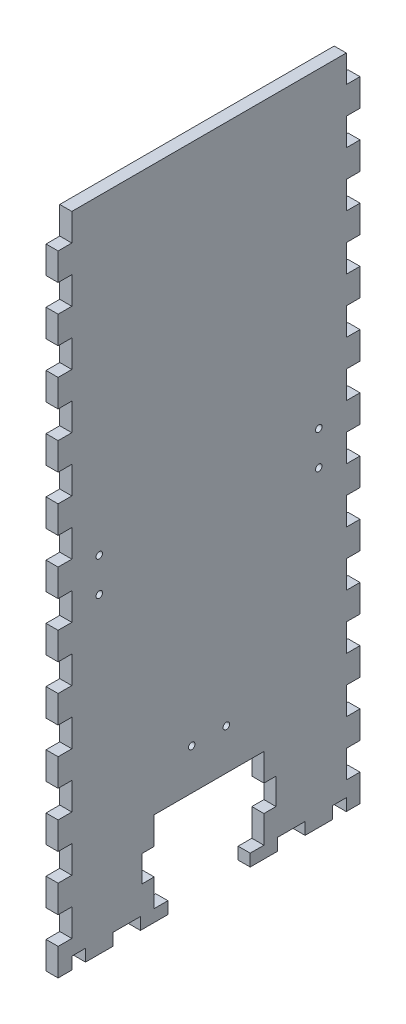
from build123d import *

# Parameters (mm, degrees)
SKETCH1_W              = 273.05
SKETCH1_H              = 139.7
BOSS_EXTRUDE1_DEPTH    = 5.588
SKETCH2_W              = 273.05
SKETCH2_H              = 139.7
SKETCH2_W_2            = 261.874
SKETCH2_H_2            = 128.524
BOSS_EXTRUDE2_DEPTH    = 298.45
SKETCH3_W              = 6.35
SKETCH3_H              = 16.933333333
SKETCH3_H_2            = 16.933333334
DOOR_SLOT_DEPTH        = 12.7
DOOR_GUIDE_HOLES_REACH = 361.255
SKETCH4_W              = 6.35
SKETCH4_H              = 15.875
LEVER_HOLES_W          = 9.652
LEVER_HOLES_H          = 6.35
LEVER_HOLES_W_2        = 6.35
CUT_EXTRUDE1_DEPTH     = 362.378293578
CUT_EXTRUDE3_REACH     = 416.577
SKETCH8_R              = 3.175
SKETCH16_W             = 327.238778096
SKETCH16_H             = 314.471565403
CUT_EXTRUDE10_DEPTH    = 362.378293578
LEFT_RIGHT_W           = 6.35
LEFT_RIGHT_H           = 5.588
LEFT_RIGHT_W_2         = 12.7
LEFT_RIGHT_H_2         = 12.66825
CUT_EXTRUDE11_DEPTH    = 415.577411883
SKETCH17_R             = 1.5
SKETCH17_W             = 23
SKETCH17_H             = 17.61800007
CUT_EXTRUDE12_DEPTH    = 313.00857951
SKETCH18_W             = 5.588
SKETCH18_H             = 12.192
CUT_EXTRUDE13_DEPTH    = 313.00857951


with BuildPart() as part:
    # Sketch1 → Boss-Extrude1 (new body)
    with BuildSketch(Plane(origin=(0, 0, 0), x_dir=(1, 0, 0), z_dir=(0, 1, 0))):
        Rectangle(SKETCH1_W, SKETCH1_H)
    extrude(amount=BOSS_EXTRUDE1_DEPTH)

    # Sketch2 → Boss-Extrude2 (add)
    with BuildSketch(Plane(origin=(0, 5.588, 0), x_dir=(1, 0, 0), z_dir=(0, 1, 0))):
        Rectangle(SKETCH2_W, SKETCH2_H)
        Rectangle(SKETCH2_W_2, SKETCH2_H_2, mode=Mode.SUBTRACT)
    extrude(amount=BOSS_EXTRUDE2_DEPTH)

    # Sketch3 → Door Slot (cut)
    with BuildSketch(Plane.XY.offset(69.85)):
        with BuildLine():
            Line((-29.337, 282.448), (-29.337, 5.588))
            Line((-29.337, 5.588), (-22.733, 5.588))
            Line((-22.733, 5.588), (-22.733, 291.592))
            Line((-22.733, 291.592), (-42.291, 291.592))
            Line((-42.291, 291.592), (-42.291, 284.988))
            Line((-42.291, 284.988), (-31.877, 284.988))
            ThreePointArc((-31.877, 284.988), (-30.080948776, 284.244051224), (-29.337, 282.448))
        make_face()
        with Locations((-13.208, 80.433333334)):
            Rectangle(SKETCH3_W, SKETCH3_H)
        with Locations((-13.208, 50.8)):
            Rectangle(SKETCH3_W, SKETCH3_H_2)
        with Locations((-13.208, 21.166666667)):
            Rectangle(SKETCH3_W, SKETCH3_H)
    extrude(amount=-DOOR_SLOT_DEPTH, mode=Mode.SUBTRACT)

    # Sketch4 → Door Guide Holes (cut, up to next)
    with BuildSketch(Plane.XY.offset(-64.262), mode=Mode.PRIVATE) as door_guide_holes_sk1:
        with Locations((-45.466, 283.4005)):
            Rectangle(SKETCH4_W, SKETCH4_H)
    door_guide_holes_tool1 = extrude(door_guide_holes_sk1.sketch, amount=-DOOR_GUIDE_HOLES_REACH, mode=Mode.PRIVATE) & part.part
    # Sketch4 → Door Guide Holes (cut, up to next)
    with BuildSketch(Plane.XY.offset(-64.262), mode=Mode.PRIVATE) as door_guide_holes_sk2:
        with Locations((-45.466, 254.8255)):
            Rectangle(SKETCH4_W, SKETCH4_H)
    door_guide_holes_tool2 = extrude(door_guide_holes_sk2.sketch, amount=-DOOR_GUIDE_HOLES_REACH, mode=Mode.PRIVATE) & part.part
    # Sketch4 → Door Guide Holes (cut, up to next)
    with BuildSketch(Plane.XY.offset(-64.262), mode=Mode.PRIVATE) as door_guide_holes_sk3:
        with Locations((-45.466, 226.2505)):
            Rectangle(SKETCH4_W, SKETCH4_H)
    door_guide_holes_tool3 = extrude(door_guide_holes_sk3.sketch, amount=-DOOR_GUIDE_HOLES_REACH, mode=Mode.PRIVATE) & part.part
    # Sketch4 → Door Guide Holes (cut, up to next)
    with BuildSketch(Plane.XY.offset(-64.262), mode=Mode.PRIVATE) as door_guide_holes_sk4:
        with Locations((-45.466, 197.6755)):
            Rectangle(SKETCH4_W, SKETCH4_H)
    door_guide_holes_tool4 = extrude(door_guide_holes_sk4.sketch, amount=-DOOR_GUIDE_HOLES_REACH, mode=Mode.PRIVATE) & part.part
    # Sketch4 → Door Guide Holes (cut, up to next)
    with BuildSketch(Plane.XY.offset(-64.262), mode=Mode.PRIVATE) as door_guide_holes_sk5:
        with Locations((-45.466, 169.1005)):
            Rectangle(SKETCH4_W, SKETCH4_H)
    door_guide_holes_tool5 = extrude(door_guide_holes_sk5.sketch, amount=-DOOR_GUIDE_HOLES_REACH, mode=Mode.PRIVATE) & part.part
    # Sketch4 → Door Guide Holes (cut, up to next)
    with BuildSketch(Plane.XY.offset(-64.262), mode=Mode.PRIVATE) as door_guide_holes_sk6:
        with Locations((-45.466, 140.5255)):
            Rectangle(SKETCH4_W, SKETCH4_H)
    door_guide_holes_tool6 = extrude(door_guide_holes_sk6.sketch, amount=-DOOR_GUIDE_HOLES_REACH, mode=Mode.PRIVATE) & part.part
    # Sketch4 → Door Guide Holes (cut, up to next)
    with BuildSketch(Plane.XY.offset(-64.262), mode=Mode.PRIVATE) as door_guide_holes_sk7:
        with Locations((-45.466, 111.9505)):
            Rectangle(SKETCH4_W, SKETCH4_H)
    door_guide_holes_tool7 = extrude(door_guide_holes_sk7.sketch, amount=-DOOR_GUIDE_HOLES_REACH, mode=Mode.PRIVATE) & part.part
    # Sketch4 → Door Guide Holes (cut, up to next)
    with BuildSketch(Plane.XY.offset(-64.262), mode=Mode.PRIVATE) as door_guide_holes_sk8:
        with Locations((-45.466, 83.3755)):
            Rectangle(SKETCH4_W, SKETCH4_H)
    door_guide_holes_tool8 = extrude(door_guide_holes_sk8.sketch, amount=-DOOR_GUIDE_HOLES_REACH, mode=Mode.PRIVATE) & part.part
    # Sketch4 → Door Guide Holes (cut, up to next)
    with BuildSketch(Plane.XY.offset(-64.262), mode=Mode.PRIVATE) as door_guide_holes_sk9:
        with Locations((-45.466, 54.8005)):
            Rectangle(SKETCH4_W, SKETCH4_H)
    door_guide_holes_tool9 = extrude(door_guide_holes_sk9.sketch, amount=-DOOR_GUIDE_HOLES_REACH, mode=Mode.PRIVATE) & part.part
    # Sketch4 → Door Guide Holes (cut, up to next)
    with BuildSketch(Plane.XY.offset(-64.262), mode=Mode.PRIVATE) as door_guide_holes_sk10:
        with Locations((-45.466, 26.2255)):
            Rectangle(SKETCH4_W, SKETCH4_H)
    door_guide_holes_tool10 = extrude(door_guide_holes_sk10.sketch, amount=-DOOR_GUIDE_HOLES_REACH, mode=Mode.PRIVATE) & part.part
    door_guide_holes_1 = door_guide_holes_tool1.solids().sort_by_distance((-45.466, 283.4005, -64.262))[0]
    add(door_guide_holes_1, mode=Mode.SUBTRACT)
    door_guide_holes_2 = door_guide_holes_tool2.solids().sort_by_distance((-45.466, 254.8255, -64.262))[0]
    add(door_guide_holes_2, mode=Mode.SUBTRACT)
    door_guide_holes_3 = door_guide_holes_tool3.solids().sort_by_distance((-45.466, 226.2505, -64.262))[0]
    add(door_guide_holes_3, mode=Mode.SUBTRACT)
    door_guide_holes_4 = door_guide_holes_tool4.solids().sort_by_distance((-45.466, 197.6755, -64.262))[0]
    add(door_guide_holes_4, mode=Mode.SUBTRACT)
    door_guide_holes_5 = door_guide_holes_tool5.solids().sort_by_distance((-45.466, 169.1005, -64.262))[0]
    add(door_guide_holes_5, mode=Mode.SUBTRACT)
    door_guide_holes_6 = door_guide_holes_tool6.solids().sort_by_distance((-45.466, 140.5255, -64.262))[0]
    add(door_guide_holes_6, mode=Mode.SUBTRACT)
    door_guide_holes_7 = door_guide_holes_tool7.solids().sort_by_distance((-45.466, 111.9505, -64.262))[0]
    add(door_guide_holes_7, mode=Mode.SUBTRACT)
    door_guide_holes_8 = door_guide_holes_tool8.solids().sort_by_distance((-45.466, 83.3755, -64.262))[0]
    add(door_guide_holes_8, mode=Mode.SUBTRACT)
    door_guide_holes_9 = door_guide_holes_tool9.solids().sort_by_distance((-45.466, 54.8005, -64.262))[0]
    add(door_guide_holes_9, mode=Mode.SUBTRACT)
    door_guide_holes_10 = door_guide_holes_tool10.solids().sort_by_distance((-45.466, 26.2255, -64.262))[0]
    add(door_guide_holes_10, mode=Mode.SUBTRACT)
    door_guide_holes = door_guide_holes_1 + door_guide_holes_2 + door_guide_holes_3 + door_guide_holes_4 + door_guide_holes_5 + door_guide_holes_6 + door_guide_holes_7 + door_guide_holes_8 + door_guide_holes_9 + door_guide_holes_10  # Door Guide Holes as one shape, for the pattern or mirror that repeats it

    # Mirror1: Door Guide Holes across plane
    add(door_guide_holes.mirror(Plane.ZY.offset(32.512)), mode=Mode.SUBTRACT)

    # Lever Holes → Cut-Extrude1 (cut, through all)
    with BuildSketch(Plane.XY.offset(69.85)):
        with Locations((54.102, 28.575)):
            Rectangle(LEVER_HOLES_W, LEVER_HOLES_H)
        with Locations((39.3065, 15.875)):
            Rectangle(LEVER_HOLES_W_2, LEVER_HOLES_H)
        with Locations((68.8975, 15.875)):
            Rectangle(LEVER_HOLES_W_2, LEVER_HOLES_H)
    extrude(amount=-CUT_EXTRUDE1_DEPTH, mode=Mode.SUBTRACT)

    # Sketch8 → Cut-Extrude3 (cut, up to next)
    with BuildSketch(Plane.ZY.offset(136.525), mode=Mode.PRIVATE) as cut_extrude3_sk1:
        with Locations((0, 19.05)):
            Circle(SKETCH8_R)
    cut_extrude3_tool1 = extrude(cut_extrude3_sk1.sketch, amount=-CUT_EXTRUDE3_REACH, mode=Mode.PRIVATE) & part.part
    add(cut_extrude3_tool1.solids().sort_by_distance((-136.525, 19.05, 0))[0], mode=Mode.SUBTRACT)

    # Sketch16 → Cut-Extrude10 (cut, through all)
    with BuildSketch(Plane.XY.offset(69.85)):
        with Locations((-32.682389048, 146.802217299)):
            Rectangle(SKETCH16_W, SKETCH16_H)
    extrude(amount=-CUT_EXTRUDE10_DEPTH, mode=Mode.SUBTRACT)

    # Left/Right → Cut-Extrude11 (cut, through all)
    with BuildSketch(Plane.ZY.offset(136.525)):
        with Locations((60.325, 2.794)):
            Rectangle(LEFT_RIGHT_W, LEFT_RIGHT_H)
        with Locations((38.1, 2.794)):
            Rectangle(LEFT_RIGHT_W_2, LEFT_RIGHT_H)
        with Locations((66.675, 19.002375)):
            Rectangle(LEFT_RIGHT_W, LEFT_RIGHT_H_2)
        with Locations((12.7, 2.794)):
            Rectangle(LEFT_RIGHT_W_2, LEFT_RIGHT_H)
        with Locations((66.675, 44.338875)):
            Rectangle(LEFT_RIGHT_W, LEFT_RIGHT_H_2)
        with Locations((-12.7, 2.794)):
            Rectangle(LEFT_RIGHT_W_2, LEFT_RIGHT_H)
        with Locations((66.675, 69.675375)):
            Rectangle(LEFT_RIGHT_W, LEFT_RIGHT_H_2)
        with Locations((-38.1, 2.794)):
            Rectangle(LEFT_RIGHT_W_2, LEFT_RIGHT_H)
        with Locations((66.675, 95.011875)):
            Rectangle(LEFT_RIGHT_W, LEFT_RIGHT_H_2)
        with Locations((-60.325, 2.794)):
            Rectangle(LEFT_RIGHT_W, LEFT_RIGHT_H)
        with Locations((66.675, 120.348375)):
            Rectangle(LEFT_RIGHT_W, LEFT_RIGHT_H_2)
        with Locations((-66.675, 19.002375)):
            Rectangle(LEFT_RIGHT_W, LEFT_RIGHT_H_2)
        with Locations((66.675, 145.684875)):
            Rectangle(LEFT_RIGHT_W, LEFT_RIGHT_H_2)
        with Locations((-66.675, 44.338875)):
            Rectangle(LEFT_RIGHT_W, LEFT_RIGHT_H_2)
        with Locations((66.675, 171.021375)):
            Rectangle(LEFT_RIGHT_W, LEFT_RIGHT_H_2)
        with Locations((-66.675, 69.675375)):
            Rectangle(LEFT_RIGHT_W, LEFT_RIGHT_H_2)
        with Locations((66.675, 196.357875)):
            Rectangle(LEFT_RIGHT_W, LEFT_RIGHT_H_2)
        with Locations((-66.675, 95.011875)):
            Rectangle(LEFT_RIGHT_W, LEFT_RIGHT_H_2)
        with Locations((66.675, 221.694375)):
            Rectangle(LEFT_RIGHT_W, LEFT_RIGHT_H_2)
        with Locations((-66.675, 120.348375)):
            Rectangle(LEFT_RIGHT_W, LEFT_RIGHT_H_2)
        with Locations((66.675, 247.030875)):
            Rectangle(LEFT_RIGHT_W, LEFT_RIGHT_H_2)
        with Locations((-66.675, 145.684875)):
            Rectangle(LEFT_RIGHT_W, LEFT_RIGHT_H_2)
        with Locations((66.675, 272.367375)):
            Rectangle(LEFT_RIGHT_W, LEFT_RIGHT_H_2)
        with Locations((-66.675, 171.021375)):
            Rectangle(LEFT_RIGHT_W, LEFT_RIGHT_H_2)
        with Locations((66.675, 297.703875)):
            Rectangle(LEFT_RIGHT_W, LEFT_RIGHT_H_2)
        with Locations((-66.675, 196.357875)):
            Rectangle(LEFT_RIGHT_W, LEFT_RIGHT_H_2)
        with Locations((-66.675, 221.694375)):
            Rectangle(LEFT_RIGHT_W, LEFT_RIGHT_H_2)
        with Locations((-66.675, 247.030875)):
            Rectangle(LEFT_RIGHT_W, LEFT_RIGHT_H_2)
        with Locations((-66.675, 272.367375)):
            Rectangle(LEFT_RIGHT_W, LEFT_RIGHT_H_2)
        with Locations((-66.675, 297.703875)):
            Rectangle(LEFT_RIGHT_W, LEFT_RIGHT_H_2)
    extrude(amount=-CUT_EXTRUDE11_DEPTH, mode=Mode.SUBTRACT)

    # Sketch17 → Cut-Extrude12 (cut, through all)
    with BuildSketch(Plane(origin=(136.525, 0, 0), x_dir=(0, 0, -1), z_dir=(1, 0, 0))):
        with Locations((-8, 62.088)):
            Circle(SKETCH17_R)
        with Locations((8, 62.088)):
            Circle(SKETCH17_R)
        with Locations((-50.8, 159.894)):
            Circle(SKETCH17_R)
        with Locations((-50.8, 144.144)):
            Circle(SKETCH17_R)
        with Locations(Location((50.8, 144.144, 0), (0, 0, 180))):
            Circle(SKETCH17_R)
        with Locations(Location((50.8, 159.894, 0), (0, 0, 180))):
            Circle(SKETCH17_R)
        with Locations((0, 22.779000035)):
            Rectangle(SKETCH17_W, SKETCH17_H)
    extrude(amount=-CUT_EXTRUDE12_DEPTH, mode=Mode.SUBTRACT)

    # Sketch18 → Cut-Extrude13 (cut, through all)
    with BuildSketch(Plane(origin=(136.525, 0, 0), x_dir=(0, 0, -1), z_dir=(1, 0, 0))):
        with Locations((-28.194, 24.384)):
            Rectangle(SKETCH18_W, SKETCH18_H)
        with Locations((28.194, 24.384)):
            Rectangle(SKETCH18_W, SKETCH18_H)
        Polygon((25.4, 30.48), (25.4, 43.18), (-25.4, 43.18), (-25.4, 30.48), (-25.4, 18.288), (-25.4, 5.588), (-6.35, 5.588), (-6.35, 0), (6.35, 0), (6.35, 5.588), (25.4, 5.588), (25.4, 18.288), align=None)
    extrude(amount=-CUT_EXTRUDE13_DEPTH, mode=Mode.SUBTRACT)


solid = part.part
